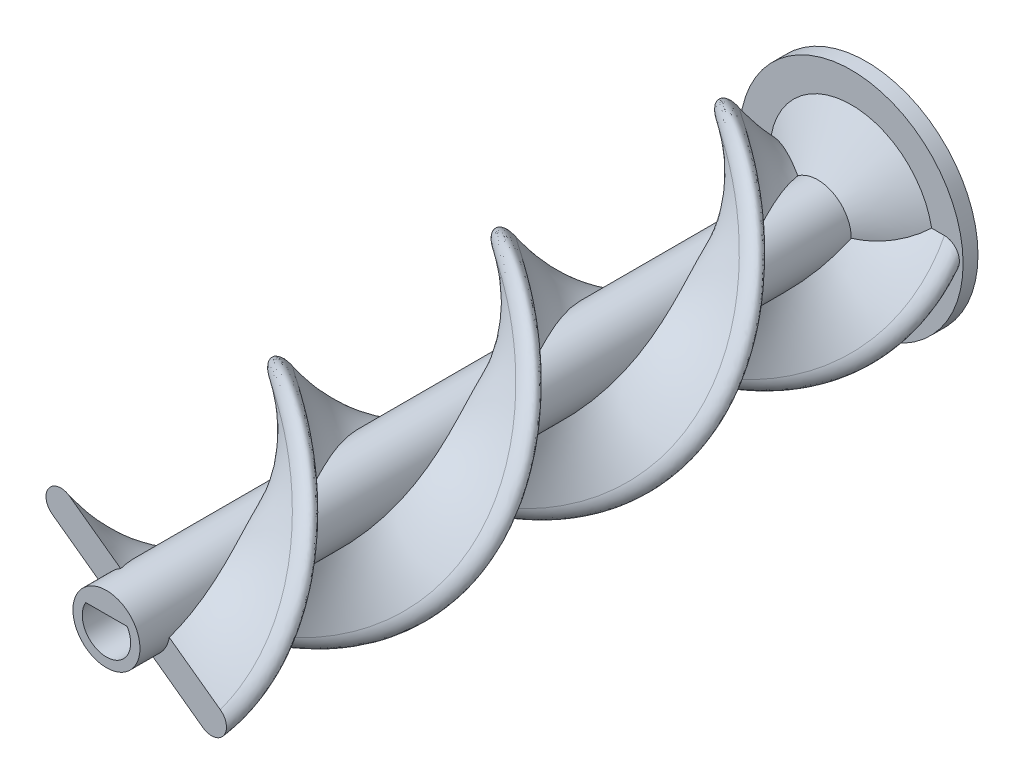
from build123d import *

# Parameters (mm, degrees)
SKETCH1_R           = 4.5
BOSS_EXTRUDE1_DEPTH = 100
SWEEP1_PITCH        = 60
SWEEP1_HEIGHT       = 96
SWEEP1_RADIUS       = 14.5
SKETCH5_R           = 15
BOSS_EXTRUDE2_DEPTH = 2
CUT_EXTRUDE1_DEPTH  = 103


with BuildPart() as part:
    # Sketch1 → Boss-Extrude1 (new body)
    with BuildSketch(Plane.XY):
        Circle(SKETCH1_R)
    extrude(amount=BOSS_EXTRUDE1_DEPTH)

    # Sweep1: sweep along a helix
    with BuildLine() as sweep1_path:
        Helix(SWEEP1_PITCH, SWEEP1_HEIGHT, SWEEP1_RADIUS, center=(0, 0, 0), direction=(0, 0, 1), lefthand=True)
    # Sketch2 → Sweep1 (sweep)
    with BuildSketch(Plane.XY):
        with BuildLine():
            Line((-12.5, 2), (12.5, 2))
            ThreePointArc((12.5, 2), (14.5, 0), (12.5, -2))
            Line((12.5, -2), (-12.5, -2))
            ThreePointArc((-12.5, -2), (-14.5, 0), (-12.5, 2))
        make_face()
    sweep(path=sweep1_path.line, is_frenet=True)

    # Sketch5 → Boss-Extrude2 (add)
    with BuildSketch(Plane(origin=(0, 0, 0), x_dir=(-1, 0, 0), z_dir=(0, 0, -1))):
        Circle(SKETCH5_R)
    extrude(amount=BOSS_EXTRUDE2_DEPTH)

    # Sketch6 → Revolve1 (revolve)
    with BuildSketch(Plane(origin=(0, 0, 0), x_dir=(1, 0, 0), z_dir=(0, 1, 0))):
        Polygon((0, 0), (-10.958506173, 0), (0, -7.669205118), align=None)
    revolve(axis=Axis((0, 0, 7.669205118), (0, 0, -1)))

    # Sketch4 → Cut-Extrude1 (cut, through all)
    with BuildSketch(Plane.XY.offset(100)):
        with BuildLine():
            Line((-2.769927797, 1.7), (2.769927797, 1.7))
            ThreePointArc((2.769927797, 1.7), (0, -3.25), (-2.769927797, 1.7))
        make_face()
    extrude(amount=-CUT_EXTRUDE1_DEPTH, mode=Mode.SUBTRACT)


solid = part.part
